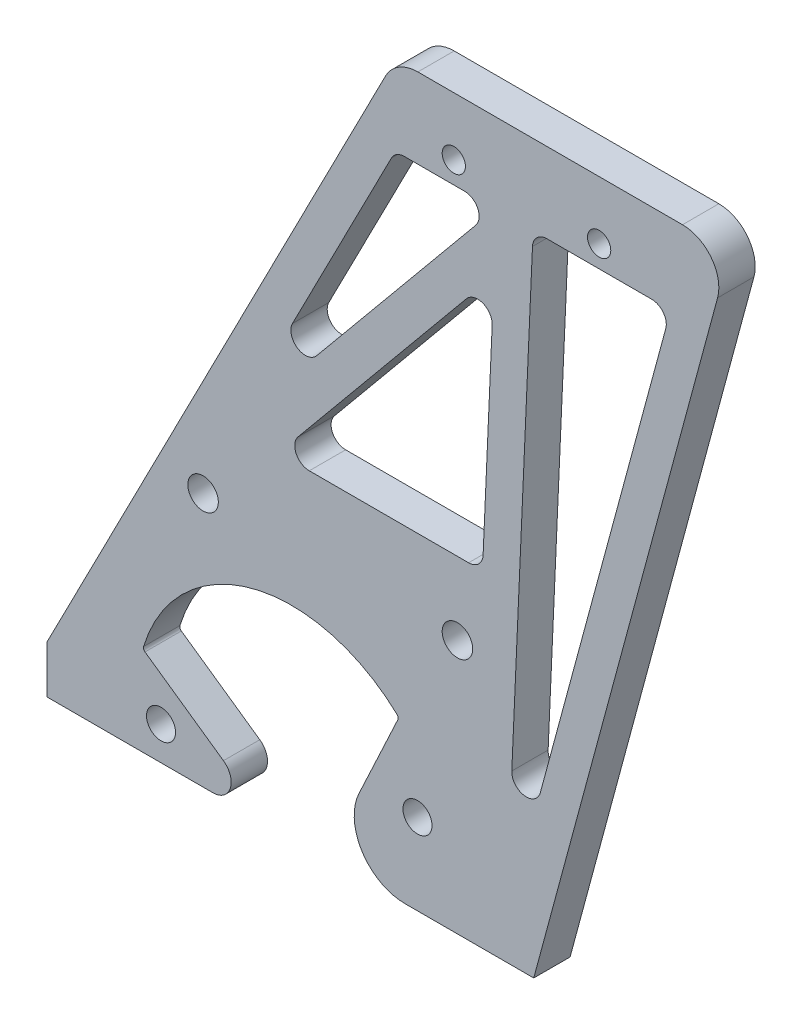
from build123d import *

# Parameters (mm, degrees)
SKETCH_1_W          = 67
SKETCH_1_H          = 30
EXTRUDE_1_DEPTH     = 5
SKETCH_3_R          = 11.5
CUT_EXTRUDE_1_DEPTH = 6
CUT_EXTRUDE_2_DEPTH = 5
EXTRUDE_2_DEPTH     = 5
FILLET_1_R          = 2.5
FILLET_3_R          = 0.5
FILLET_4_R          = 7
SKETCH_6_R          = 2
CUT_EXTRUDE_3_DEPTH = 6
EXTRUDE_3_DEPTH     = 5
CUT_EXTRUDE_4_DEPTH = 6
EXTRUDE_4_DEPTH     = 5
SKETCH_10_R         = 2.1
CUT_EXTRUDE_5_DEPTH = 6
FILLET_5_R          = 5
SKETCH_11_R         = 1.6
CUT_EXTRUDE_6_DEPTH = 6
CUT_EXTRUDE_7_DEPTH = 10
FILLET_6_R          = 2


with BuildPart() as part:
    # 草图1 → 凸台-拉伸1 (new body)
    with BuildSketch(Plane.XY):
        Rectangle(SKETCH_1_W, SKETCH_1_H)
    extrude(amount=EXTRUDE_1_DEPTH)

    # 草图3 → 切除-拉伸1 (cut, through all)
    with BuildSketch(Plane.XY.offset(5)):
        with Locations((0.155997342, -18.5)):
            Circle(SKETCH_3_R)
    extrude(amount=-CUT_EXTRUDE_1_DEPTH, mode=Mode.SUBTRACT)

    # 草图4 → 切除-拉伸2 (cut)
    with BuildSketch(Plane.XY.offset(5)):
        with BuildLine():
            Line((14.951296016, -3.246749948), (0.155997342, -34.975370344))
            Line((0.155997342, -34.975370344), (0.155997342, -27))
            Line((0.155997342, -27), (-20.283732192, -12.687947301))
            ThreePointArc((-20.283732192, -12.687947301), (-5.343907366, 2.025923809), (14.951296016, -3.246749948))
        make_face()
    extrude(amount=-CUT_EXTRUDE_2_DEPTH, mode=Mode.SUBTRACT)

    # 草图5 → 凸台-拉伸2 (add)
    with BuildSketch(Plane.XY.offset(5)):
        Polygon((-16.981778738, -15), (-2.700298671, -25), (-33.5, -25), (-33.5, -15), align=None)
        Polygon((33.5, -15), (33.5, -25), (4.807588927, -25), (10.334473164, -13.147558505), align=None)
    extrude(amount=-EXTRUDE_2_DEPTH)

    # 圆角1
    fillet_1_edges = [part.edges().sort_by_distance(p)[0] for p in [
        (-2.700298671, -25, 2.5),
    ]]
    fillet(fillet_1_edges, radius=FILLET_1_R)

    # 圆角3
    fillet_3_edges = [part.edges().sort_by_distance(p)[0] for p in [
        (14.951296016, -3.246749948, 2.5),
        (-20.283732192, -12.687947301, 2.5),
    ]]
    fillet(fillet_3_edges, radius=FILLET_3_R)

    # 圆角4
    fillet_4_edges = [part.edges().sort_by_distance(p)[0] for p in [
        (4.807588927, -25, 2.5),
    ]]
    fillet(fillet_4_edges, radius=FILLET_4_R)

    # 草图6 → 切除-拉伸3 (cut, through all)
    with BuildSketch(Plane.XY.offset(5)):
        with Locations((17.505658254, -13.841257188)):
            Circle(SKETCH_6_R)
        with Locations((-17.782400736, -20.381512339)):
            Circle(SKETCH_6_R)
    extrude(amount=-CUT_EXTRUDE_3_DEPTH, mode=Mode.SUBTRACT)

    # 草图7 → 凸台-拉伸3 (add)
    with BuildSketch(Plane.XY.offset(5)):
        Polygon((60.5, 75), (14.5, 75), (-16.303792618, 15), (33.5, 15), align=None)
    extrude(amount=-EXTRUDE_3_DEPTH)

    # 草图8 → 切除-拉伸4 (cut, through all)
    with BuildSketch(Plane.XY.offset(5)):
        Polygon((-16.303792618, 15), (-33.5, -18.49498082), (-33.5, 15), align=None)
    extrude(amount=-CUT_EXTRUDE_4_DEPTH, mode=Mode.SUBTRACT)

    # 草图9 → 凸台-拉伸4 (add)
    with BuildSketch(Plane.XY.offset(5)):
        Polygon((60.5, 75), (33.5, -25), (33.5, 15), align=None)
    extrude(amount=-EXTRUDE_4_DEPTH)

    # 草图10 → 切除-拉伸5 (cut, through all)
    with BuildSketch(Plane.XY.offset(5)):
        with Locations((-12, 10)):
            Circle(SKETCH_10_R)
        with Locations((23, 10)):
            Circle(SKETCH_10_R)
    extrude(amount=-CUT_EXTRUDE_5_DEPTH, mode=Mode.SUBTRACT)

    # 圆角5
    fillet_5_edges = [part.edges().sort_by_distance(p)[0] for p in [
        (60.5, 75, 2.5),
        (14.5, 75, 2.5),
    ]]
    fillet(fillet_5_edges, radius=FILLET_5_R)

    # 草图11 → 切除-拉伸6 (cut, through all)
    with BuildSketch(Plane.XY.offset(5)):
        with Locations((42.500000039, 67)):
            Circle(SKETCH_11_R)
        with Locations((22.500000039, 67)):
            Circle(SKETCH_11_R)
    extrude(amount=-CUT_EXTRUDE_6_DEPTH, mode=Mode.SUBTRACT)

    # 草图12 → 切除-拉伸7 (cut)
    with BuildSketch(Plane.XY.offset(5)):
        Polygon((33.412019277, 64), (31.452414539, 20), (29.670955687, -20), (52.350955687, 64), align=None)
        Polygon((28.047412755, 55.924590701), (-1.630833947, 20), (26.447458252, 20), align=None)
        Polygon((14.473082867, 64), (-8.116365053, 20), (28.233189094, 64), align=None)
    extrude(amount=-CUT_EXTRUDE_7_DEPTH, mode=Mode.SUBTRACT)

    # 圆角6
    fillet_6_edges = [part.edges().sort_by_distance(p)[0] for p in [
        (29.670955687, -20, 2.5),
        (33.412019277, 64, 2.5),
        (52.350955687, 64, 2.5),
        (14.473082867, 64, 2.5),
        (28.233189094, 64, 2.5),
        (-8.116365053, 20, 2.5),
        (28.047412755, 55.924590701, 2.5),
        (26.447458252, 20, 2.5),
        (-1.630833947, 20, 2.5),
    ]]
    fillet(fillet_6_edges, radius=FILLET_6_R)


solid = part.part
